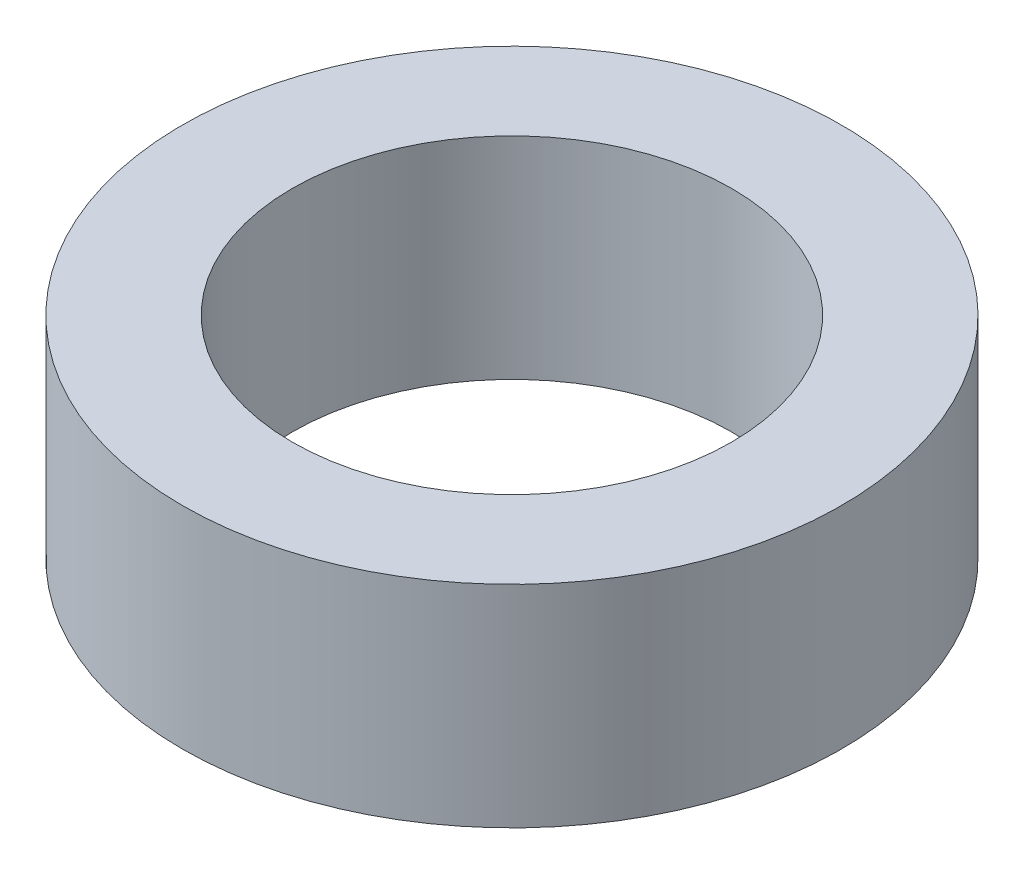
from build123d import *

# Parameters (mm, degrees)
SKETCH1_R           = 9.525
SKETCH1_R_2         = 6.35
BOSS_EXTRUDE1_DEPTH = 6.096


with BuildPart() as part:
    # Sketch1 → Boss-Extrude1 (new body)
    with BuildSketch(Plane(origin=(0, 0, 0), x_dir=(1, 0, 0), z_dir=(0, 1, 0))):
        Circle(SKETCH1_R)
        Circle(SKETCH1_R_2, mode=Mode.SUBTRACT)
    extrude(amount=BOSS_EXTRUDE1_DEPTH)


solid = part.part
